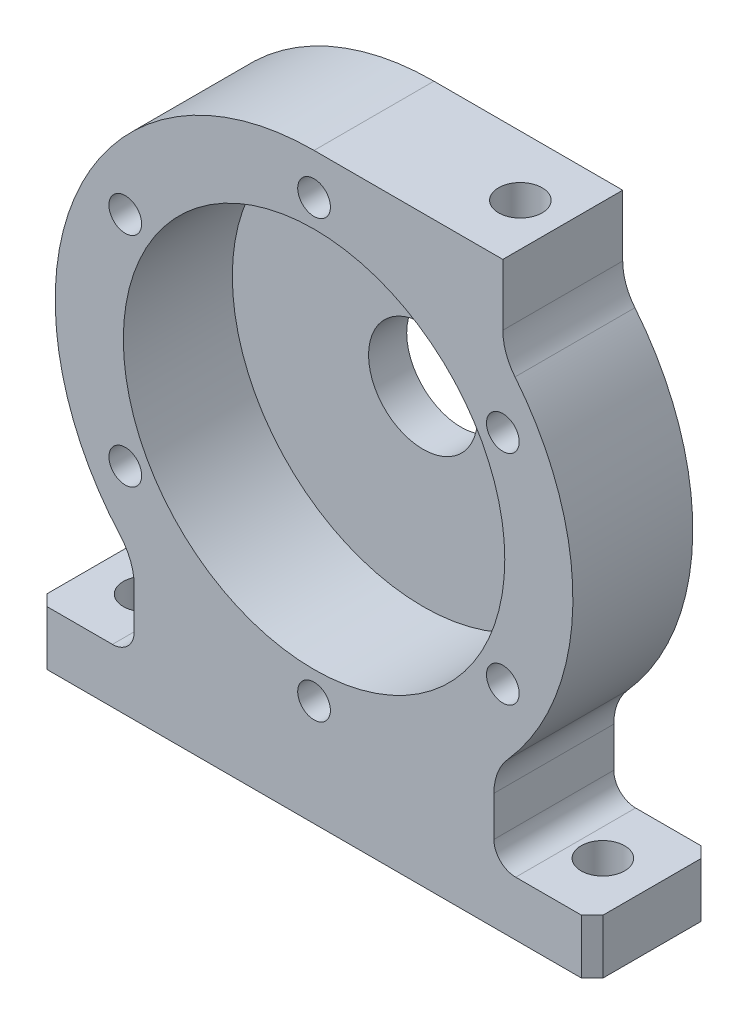
from build123d import *

# Parameters (mm, degrees)
BOSS_EXTRUDE1_DEPTH = 11
SKETCH2_R           = 35
CUT_EXTRUDE1_DEPTH  = 20
SKETCH3_R           = 14
BOSS_EXTRUDE2_DEPTH = 5
SKETCH4_R           = 10
CUT_EXTRUDE2_DEPTH  = 55
FILLET1_R           = 4
CHAMFER1_SIZE       = 2
SKETCH5_R           = 4
CUT_EXTRUDE3_DEPTH  = 10
SKETCH6_R           = 4
CUT_EXTRUDE4_DEPTH  = 31
SKETCH7_R           = 3
CUT_EXTRUDE5_DEPTH  = 6


with BuildPart() as part:
    # Sketch1 → Boss-Extrude1 (new body, symmetric)
    with BuildSketch(Plane.XY):
        with BuildLine():
            Line((-51.041834152, 0), (51.041834152, 0))
            Line((51.041834152, 0), (51.041834152, 10))
            Line((51.041834152, 10), (37, 10))
            ThreePointArc((37, 10), (34.171572875, 11.171572875), (33, 14))
            Line((33, 14), (33, 21.326056007))
            ThreePointArc((33, 21.326056007), (33.651668366, 24.876928527), (35.52173913, 27.965002788))
            ThreePointArc((35.52173913, 27.965002788), (47.48845464, 58.45277704), (36.877361169, 89.438440728))
            ThreePointArc((36.877361169, 89.438440728), (35.216671351, 92.397361701), (34.641016151, 95.741270355))
            Line((34.641016151, 95.741270355), (34.641016151, 107))
            Line((34.641016151, 107), (0, 107))
            ThreePointArc((0, 107), (-43.325294965, 78.972257605), (-35.52173913, 27.965002788))
            ThreePointArc((-35.52173913, 27.965002788), (-33.651668366, 24.876928527), (-33, 21.326056007))
            Line((-33, 21.326056007), (-33, 14))
            ThreePointArc((-33, 14), (-34.171572875, 11.171572875), (-37, 10))
            Line((-37, 10), (-51.041834152, 10))
            Line((-51.041834152, 10), (-51.041834152, 0))
        make_face()
    extrude(amount=BOSS_EXTRUDE1_DEPTH, both=True)

    # Sketch2 → Cut-Extrude1 (cut)
    with BuildSketch(Plane.XY.offset(11)):
        with Locations((0, 59.5)):
            Circle(SKETCH2_R)
    extrude(amount=-CUT_EXTRUDE1_DEPTH, mode=Mode.SUBTRACT)

    # Sketch3 → Boss-Extrude2 (add)
    with BuildSketch(Plane(origin=(0, 0, -11), x_dir=(-1, 0, 0), z_dir=(0, 0, -1))):
        with Locations((0, 59.5)):
            Circle(SKETCH3_R)
    extrude(amount=BOSS_EXTRUDE2_DEPTH)

    # Sketch4 → Cut-Extrude2 (cut)
    with BuildSketch(Plane(origin=(0, 0, -16), x_dir=(-1, 0, 0), z_dir=(0, 0, -1))):
        with Locations((0, 59.5)):
            Circle(SKETCH4_R)
    extrude(amount=-CUT_EXTRUDE2_DEPTH, mode=Mode.SUBTRACT)

    # Fillet1
    fillet1_edges = [part.edges().sort_by_distance(p)[0] for p in [
        (14, 59.5, -11),
    ]]
    fillet(fillet1_edges, radius=FILLET1_R)

    # Chamfer1
    chamfer1_edges = [part.edges().sort_by_distance(p)[0] for p in [
        (-51.041834152, 5, -11),
        (51.041834152, 5, -11),
        (51.041834152, 5, 11),
        (-51.041834152, 5, 11),
    ]]
    chamfer(chamfer1_edges, length=CHAMFER1_SIZE)

    # Sketch5 → Cut-Extrude3 (cut)
    with BuildSketch(Plane(origin=(0, 10, 0), x_dir=(1, 0, 0), z_dir=(0, 1, 0))):
        with Locations((-42, 0)):
            Circle(SKETCH5_R)
        with Locations((42, 0)):
            Circle(SKETCH5_R)
    extrude(amount=-CUT_EXTRUDE3_DEPTH, mode=Mode.SUBTRACT)

    # Sketch6 → Cut-Extrude4 (cut)
    with BuildSketch(Plane(origin=(0, 107, 0), x_dir=(1, 0, 0), z_dir=(0, 1, 0))):
        with Locations((26.861016151, 0)):
            Circle(SKETCH6_R)
    extrude(amount=-CUT_EXTRUDE4_DEPTH, mode=Mode.SUBTRACT)

    # Sketch7 → Cut-Extrude5 (cut)
    with BuildSketch(Plane.XY.offset(11)):
        with Locations((0, 99.5)):
            Circle(SKETCH7_R)
        with Locations((34.641016151, 79.5)):
            Circle(SKETCH7_R)
        with Locations((34.641016151, 39.5)):
            Circle(SKETCH7_R)
        with Locations((0, 19.5)):
            Circle(SKETCH7_R)
        with Locations((-34.641016151, 39.5)):
            Circle(SKETCH7_R)
        with Locations((-34.641016151, 79.5)):
            Circle(SKETCH7_R)
    extrude(amount=-CUT_EXTRUDE5_DEPTH, mode=Mode.SUBTRACT)


solid = part.part
